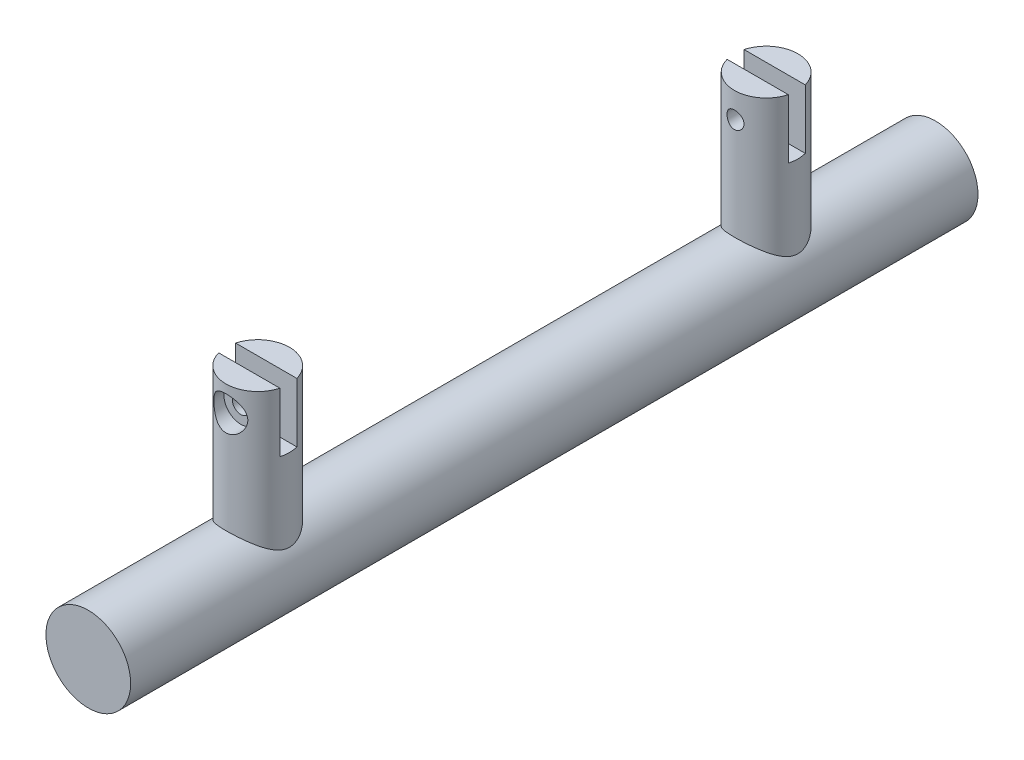
from build123d import *

# Parameters (mm, degrees)
SKETCH1_R           = 10
BOSS_EXTRUDE1_DEPTH = 100
SKETCH2_R           = 7.5
BOSS_EXTRUDE2_DEPTH = 40
SKETCH3_W           = 15
SKETCH3_H           = 4
CUT_EXTRUDE1_DEPTH  = 14
SKETCH4_R           = 2
CUT_EXTRUDE2_DEPTH  = 70
SKETCH5_R           = 4
CUT_EXTRUDE3_DEPTH  = 36
SKETCH6_R           = 4
CUT_EXTRUDE4_DEPTH  = 36


with BuildPart() as part:
    # Sketch1 → Boss-Extrude1 (new body, symmetric)
    with BuildSketch(Plane.XY):
        Circle(SKETCH1_R)
    extrude(amount=BOSS_EXTRUDE1_DEPTH, both=True)

    # Sketch2 → Boss-Extrude2 (add)
    with BuildSketch(Plane(origin=(0, 0, 0), x_dir=(1, 0, 0), z_dir=(0, 1, 0))):
        with Locations((0, 60)):
            Circle(SKETCH2_R)
        with Locations((0, -60)):
            Circle(SKETCH2_R)
    extrude(amount=BOSS_EXTRUDE2_DEPTH)

    # Sketch3 → Cut-Extrude1 (cut)
    with BuildSketch(Plane(origin=(0, 40, 0), x_dir=(1, 0, 0), z_dir=(0, 1, 0))):
        with Locations((0, -60)):
            Rectangle(SKETCH3_W, SKETCH3_H)
        with Locations((0, 60)):
            Rectangle(SKETCH3_W, SKETCH3_H)
    extrude(amount=-CUT_EXTRUDE1_DEPTH, mode=Mode.SUBTRACT)

    # Sketch4 → Cut-Extrude2 (cut, symmetric)
    with BuildSketch(Plane.XY):
        with Locations((0, 34)):
            Circle(SKETCH4_R)
    extrude(amount=CUT_EXTRUDE2_DEPTH, both=True, mode=Mode.SUBTRACT)

    # Sketch5 → Cut-Extrude3 (cut)
    with BuildSketch(Plane(origin=(0, 0, -100), x_dir=(-1, 0, 0), z_dir=(0, 0, -1))):
        with Locations((0, 34)):
            Circle(SKETCH5_R)
    extrude(amount=-CUT_EXTRUDE3_DEPTH, mode=Mode.SUBTRACT)

    # Sketch6 → Cut-Extrude4 (cut)
    with BuildSketch(Plane.XY.offset(100)):
        with Locations((0, 34)):
            Circle(SKETCH6_R)
    extrude(amount=-CUT_EXTRUDE4_DEPTH, mode=Mode.SUBTRACT)


solid = part.part
